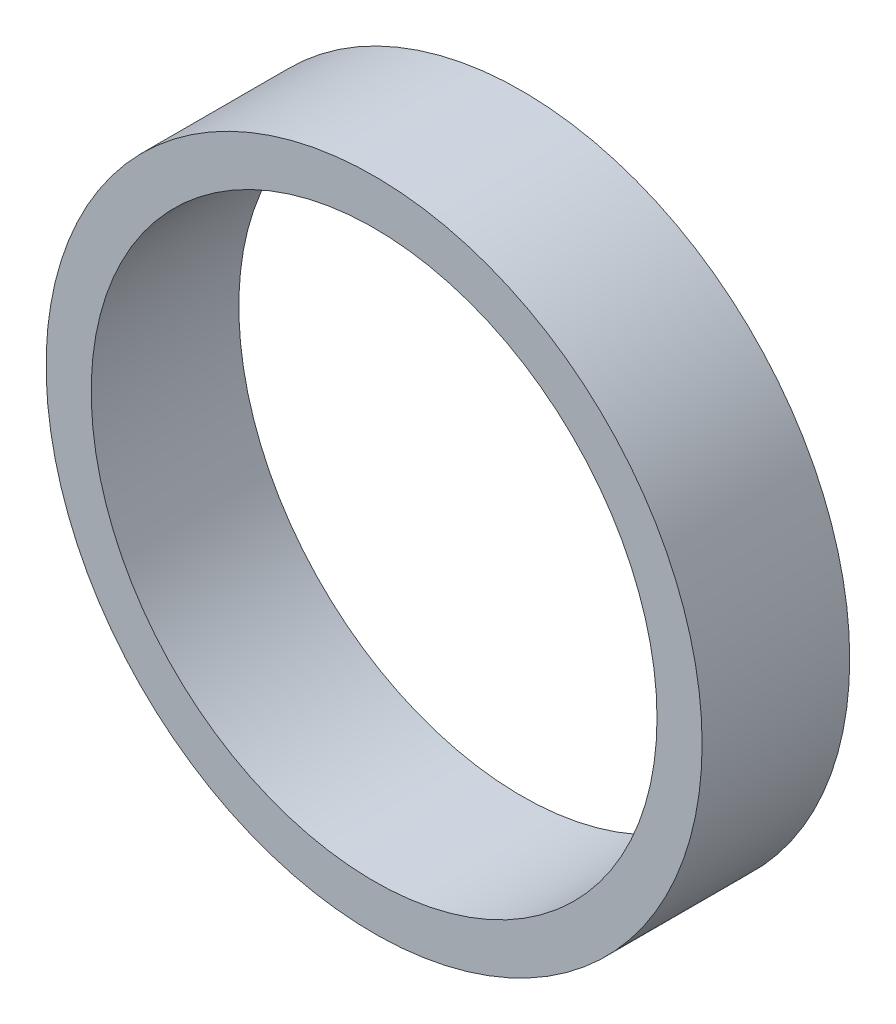
from build123d import *

# Parameters (mm, degrees)
SKETCH1_R           = 20
BOSS_EXTRUDE1_DEPTH = 4.5
SKETCH2_R           = 17.25
CUT_EXTRUDE1_DEPTH  = 9


with BuildPart() as part:
    # Sketch1 → Boss-Extrude1 (new body, symmetric)
    with BuildSketch(Plane.XY):
        Circle(SKETCH1_R)
    extrude(amount=BOSS_EXTRUDE1_DEPTH, both=True)

    # Sketch2 → Cut-Extrude1 (cut)
    with BuildSketch(Plane.XY.offset(4.5)):
        Circle(SKETCH2_R)
    extrude(amount=-CUT_EXTRUDE1_DEPTH, mode=Mode.SUBTRACT)


solid = part.part
